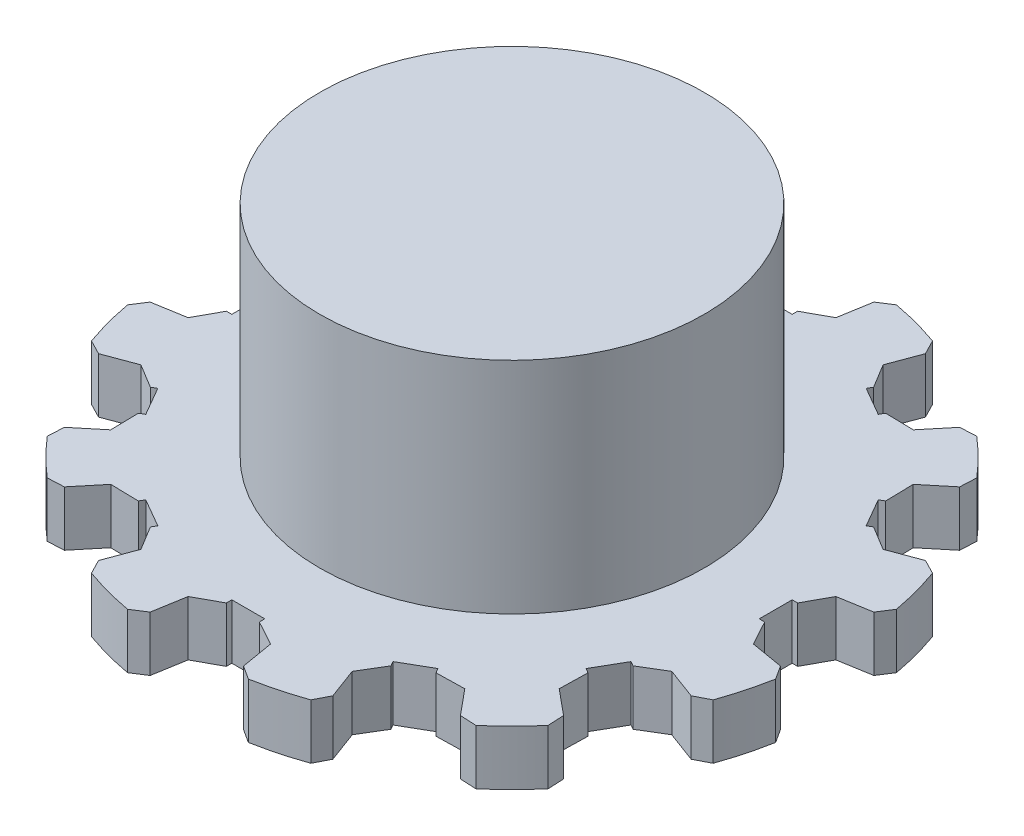
from build123d import *

# Parameters (mm, degrees)
BOSS_EXTRUDE1_DEPTH = 5
SKETCH2_R           = 17.5
BOSS_EXTRUDE3_DEPTH = 20


with BuildPart() as part:
    # Sketch1 → Boss-Extrude1 (new body)
    with BuildSketch(Plane(origin=(0, 0, 0), x_dir=(1, 0, 0), z_dir=(0, 1, 0))):
        with BuildLine():
            Line((-1.5, 24.494818027), (-3.75, 25.728146066))
            Line((-3.75, 25.728146066), (-4.25, 28.686887248))
            Line((-4.25, 28.686887248), (-5.5, 29.491524206))
            ThreePointArc((-5.5, 29.491524206), (-6.518225952, 29.283318296), (-7.528629065, 29.039968051))
            ThreePointArc((-7.528629065, 29.039968051), (-7.764571353, 28.977774789), (-8, 28.91366459))
            ThreePointArc((-8, 28.91366459), (-8.996709886, 28.619210528), (-9.982622382, 28.290409159))
            Line((-9.982622382, 28.290409159), (-10.662835658, 26.968573113))
            Line((-10.662835658, 26.968573113), (-9.616477769, 24.156228086))
            Line((-9.616477769, 24.156228086), (-10.948370908, 21.963134673))
            Line((-10.948370908, 21.963134673), (-10.700961894, 21.534609691))
            Line((-10.700961894, 21.534609691), (-13.299038106, 20.034609691))
            Line((-13.299038106, 20.034609691), (-13.546447119, 20.463134673))
            Line((-13.546447119, 20.463134673), (-16.111668297, 20.406228086))
            Line((-16.111668297, 20.406228086), (-18.02405159, 22.718573113))
            Line((-18.02405159, 22.718573113), (-19.508901824, 22.790409159))
            ThreePointArc((-19.508901824, 22.790409159), (-20.28660841, 22.100984575), (-21.039968051, 21.385035525))
            ThreePointArc((-21.039968051, 21.385035525), (-21.213203436, 21.213203436), (-21.385035525, 21.039968051))
            ThreePointArc((-21.385035525, 21.039968051), (-22.100984575, 20.28660841), (-22.790409159, 19.508901824))
            Line((-22.790409159, 19.508901824), (-22.718573113, 18.02405159))
            Line((-22.718573113, 18.02405159), (-20.406228086, 16.111668297))
            Line((-20.406228086, 16.111668297), (-20.463134673, 13.546447119))
            Line((-20.463134673, 13.546447119), (-20.034609691, 13.299038106))
            Line((-20.034609691, 13.299038106), (-21.534609691, 10.700961894))
            Line((-21.534609691, 10.700961894), (-21.963134673, 10.948370908))
            Line((-21.963134673, 10.948370908), (-24.156228086, 9.616477769))
            Line((-24.156228086, 9.616477769), (-26.968573113, 10.662835658))
            Line((-26.968573113, 10.662835658), (-28.290409159, 9.982622382))
            ThreePointArc((-28.290409159, 9.982622382), (-28.619210528, 8.996709886), (-28.91366459, 8))
            ThreePointArc((-28.91366459, 8), (-28.977774789, 7.764571353), (-29.039968051, 7.528629065))
            ThreePointArc((-29.039968051, 7.528629065), (-29.283318296, 6.518225952), (-29.491524206, 5.5))
            Line((-29.491524206, 5.5), (-28.686887248, 4.25))
            Line((-28.686887248, 4.25), (-25.728146066, 3.75))
            Line((-25.728146066, 3.75), (-24.494818027, 1.5))
            Line((-24.494818027, 1.5), (-24, 1.5))
            Line((-24, 1.5), (-24, -1.5))
            Line((-24, -1.5), (-24.494818027, -1.5))
            Line((-24.494818027, -1.5), (-25.728146066, -3.75))
            Line((-25.728146066, -3.75), (-28.686887248, -4.25))
            Line((-28.686887248, -4.25), (-29.491524206, -5.5))
            ThreePointArc((-29.491524206, -5.5), (-29.283318296, -6.518225952), (-29.039968051, -7.528629065))
            ThreePointArc((-29.039968051, -7.528629065), (-28.977774789, -7.764571353), (-28.91366459, -8))
            ThreePointArc((-28.91366459, -8), (-28.619210528, -8.996709886), (-28.290409159, -9.982622382))
            Line((-28.290409159, -9.982622382), (-26.968573113, -10.662835658))
            Line((-26.968573113, -10.662835658), (-24.156228086, -9.616477769))
            Line((-24.156228086, -9.616477769), (-21.963134673, -10.948370908))
            Line((-21.963134673, -10.948370908), (-21.534609691, -10.700961894))
            Line((-21.534609691, -10.700961894), (-20.034609691, -13.299038106))
            Line((-20.034609691, -13.299038106), (-20.463134673, -13.546447119))
            Line((-20.463134673, -13.546447119), (-20.406228086, -16.111668297))
            Line((-20.406228086, -16.111668297), (-22.718573113, -18.02405159))
            Line((-22.718573113, -18.02405159), (-22.790409159, -19.508901824))
            ThreePointArc((-22.790409159, -19.508901824), (-22.100984575, -20.28660841), (-21.385035525, -21.039968051))
            ThreePointArc((-21.385035525, -21.039968051), (-21.213203436, -21.213203436), (-21.039968051, -21.385035525))
            ThreePointArc((-21.039968051, -21.385035525), (-20.28660841, -22.100984575), (-19.508901824, -22.790409159))
            Line((-19.508901824, -22.790409159), (-18.02405159, -22.718573113))
            Line((-18.02405159, -22.718573113), (-16.111668297, -20.406228086))
            Line((-16.111668297, -20.406228086), (-13.546447119, -20.463134673))
            Line((-13.546447119, -20.463134673), (-13.299038106, -20.034609691))
            Line((-13.299038106, -20.034609691), (-10.700961894, -21.534609691))
            Line((-10.700961894, -21.534609691), (-10.948370908, -21.963134673))
            Line((-10.948370908, -21.963134673), (-9.616477769, -24.156228086))
            Line((-9.616477769, -24.156228086), (-10.662835658, -26.968573113))
            Line((-10.662835658, -26.968573113), (-9.982622382, -28.290409159))
            ThreePointArc((-9.982622382, -28.290409159), (-8.996709886, -28.619210528), (-8, -28.91366459))
            ThreePointArc((-8, -28.91366459), (-7.764571353, -28.977774789), (-7.528629065, -29.039968051))
            ThreePointArc((-7.528629065, -29.039968051), (-6.518225952, -29.283318296), (-5.5, -29.491524206))
            Line((-5.5, -29.491524206), (-4.25, -28.686887248))
            Line((-4.25, -28.686887248), (-3.75, -25.728146066))
            Line((-3.75, -25.728146066), (-1.5, -24.494818027))
            Line((-1.5, -24.494818027), (-1.5, -24))
            Line((-1.5, -24), (1.5, -24))
            Line((1.5, -24), (1.5, -24.494818027))
            Line((1.5, -24.494818027), (3.75, -25.728146066))
            Line((3.75, -25.728146066), (4.25, -28.686887248))
            Line((4.25, -28.686887248), (5.5, -29.491524206))
            ThreePointArc((5.5, -29.491524206), (6.518225952, -29.283318296), (7.528629065, -29.039968051))
            ThreePointArc((7.528629065, -29.039968051), (7.764571353, -28.977774789), (8, -28.91366459))
            ThreePointArc((8, -28.91366459), (8.996709886, -28.619210528), (9.982622382, -28.290409159))
            Line((9.982622382, -28.290409159), (10.662835658, -26.968573113))
            Line((10.662835658, -26.968573113), (9.616477769, -24.156228086))
            Line((9.616477769, -24.156228086), (10.948370908, -21.963134673))
            Line((10.948370908, -21.963134673), (10.700961894, -21.534609691))
            Line((10.700961894, -21.534609691), (13.299038106, -20.034609691))
            Line((13.299038106, -20.034609691), (13.546447119, -20.463134673))
            Line((13.546447119, -20.463134673), (16.111668297, -20.406228086))
            Line((16.111668297, -20.406228086), (18.02405159, -22.718573113))
            Line((18.02405159, -22.718573113), (19.508901824, -22.790409159))
            ThreePointArc((19.508901824, -22.790409159), (20.28660841, -22.100984575), (21.039968051, -21.385035525))
            ThreePointArc((21.039968051, -21.385035525), (21.213203436, -21.213203436), (21.385035525, -21.039968051))
            ThreePointArc((21.385035525, -21.039968051), (22.100984575, -20.28660841), (22.790409159, -19.508901824))
            Line((22.790409159, -19.508901824), (22.718573113, -18.02405159))
            Line((22.718573113, -18.02405159), (20.406228086, -16.111668297))
            Line((20.406228086, -16.111668297), (20.463134673, -13.546447119))
            Line((20.463134673, -13.546447119), (20.034609691, -13.299038106))
            Line((20.034609691, -13.299038106), (21.534609691, -10.700961894))
            Line((21.534609691, -10.700961894), (21.963134673, -10.948370908))
            Line((21.963134673, -10.948370908), (24.156228086, -9.616477769))
            Line((24.156228086, -9.616477769), (26.968573113, -10.662835658))
            Line((26.968573113, -10.662835658), (28.290409159, -9.982622382))
            ThreePointArc((28.290409159, -9.982622382), (28.619210528, -8.996709886), (28.91366459, -8))
            ThreePointArc((28.91366459, -8), (28.977774789, -7.764571353), (29.039968051, -7.528629065))
            ThreePointArc((29.039968051, -7.528629065), (29.283318296, -6.518225952), (29.491524206, -5.5))
            Line((29.491524206, -5.5), (28.686887248, -4.25))
            Line((28.686887248, -4.25), (25.728146066, -3.75))
            Line((25.728146066, -3.75), (24.494818027, -1.5))
            Line((24.494818027, -1.5), (24, -1.5))
            Line((24, -1.5), (24, 1.5))
            Line((24, 1.5), (24.494818027, 1.5))
            Line((24.494818027, 1.5), (25.728146066, 3.75))
            Line((25.728146066, 3.75), (28.686887248, 4.25))
            Line((28.686887248, 4.25), (29.491524206, 5.5))
            ThreePointArc((29.491524206, 5.5), (29.283318296, 6.518225952), (29.039968051, 7.528629065))
            ThreePointArc((29.039968051, 7.528629065), (28.977774789, 7.764571353), (28.91366459, 8))
            ThreePointArc((28.91366459, 8), (28.619210528, 8.996709886), (28.290409159, 9.982622382))
            Line((28.290409159, 9.982622382), (26.968573113, 10.662835658))
            Line((26.968573113, 10.662835658), (24.156228086, 9.616477769))
            Line((24.156228086, 9.616477769), (21.963134673, 10.948370908))
            Line((21.963134673, 10.948370908), (21.534609691, 10.700961894))
            Line((21.534609691, 10.700961894), (20.034609691, 13.299038106))
            Line((20.034609691, 13.299038106), (20.463134673, 13.546447119))
            Line((20.463134673, 13.546447119), (20.406228086, 16.111668297))
            Line((20.406228086, 16.111668297), (22.718573113, 18.02405159))
            Line((22.718573113, 18.02405159), (22.790409159, 19.508901824))
            ThreePointArc((22.790409159, 19.508901824), (22.100984575, 20.28660841), (21.385035525, 21.039968051))
            ThreePointArc((21.385035525, 21.039968051), (21.213203436, 21.213203436), (21.039968051, 21.385035525))
            ThreePointArc((21.039968051, 21.385035525), (20.28660841, 22.100984575), (19.508901824, 22.790409159))
            Line((19.508901824, 22.790409159), (18.02405159, 22.718573113))
            Line((18.02405159, 22.718573113), (16.111668297, 20.406228086))
            Line((16.111668297, 20.406228086), (13.546447119, 20.463134673))
            Line((13.546447119, 20.463134673), (13.299038106, 20.034609691))
            Line((13.299038106, 20.034609691), (10.700961894, 21.534609691))
            Line((10.700961894, 21.534609691), (10.948370908, 21.963134673))
            Line((10.948370908, 21.963134673), (9.616477769, 24.156228086))
            Line((9.616477769, 24.156228086), (10.662835658, 26.968573113))
            Line((10.662835658, 26.968573113), (9.982622382, 28.290409159))
            ThreePointArc((9.982622382, 28.290409159), (8.996709886, 28.619210528), (8, 28.91366459))
            ThreePointArc((8, 28.91366459), (7.764571353, 28.977774789), (7.528629065, 29.039968051))
            ThreePointArc((7.528629065, 29.039968051), (6.518225952, 29.283318296), (5.5, 29.491524206))
            Line((5.5, 29.491524206), (4.25, 28.686887248))
            Line((4.25, 28.686887248), (3.75, 25.728146066))
            Line((3.75, 25.728146066), (1.5, 24.494818027))
            Line((1.5, 24.494818027), (1.5, 24))
            Line((1.5, 24), (-1.5, 24))
            Line((-1.5, 24), (-1.5, 24.494818027))
        make_face()
    extrude(amount=BOSS_EXTRUDE1_DEPTH)

    # Sketch2 → Boss-Extrude3 (add)
    with BuildSketch(Plane(origin=(0, 5, 0), x_dir=(1, 0, 0), z_dir=(0, 1, 0))):
        Circle(SKETCH2_R)
    extrude(amount=BOSS_EXTRUDE3_DEPTH)


solid = part.part
